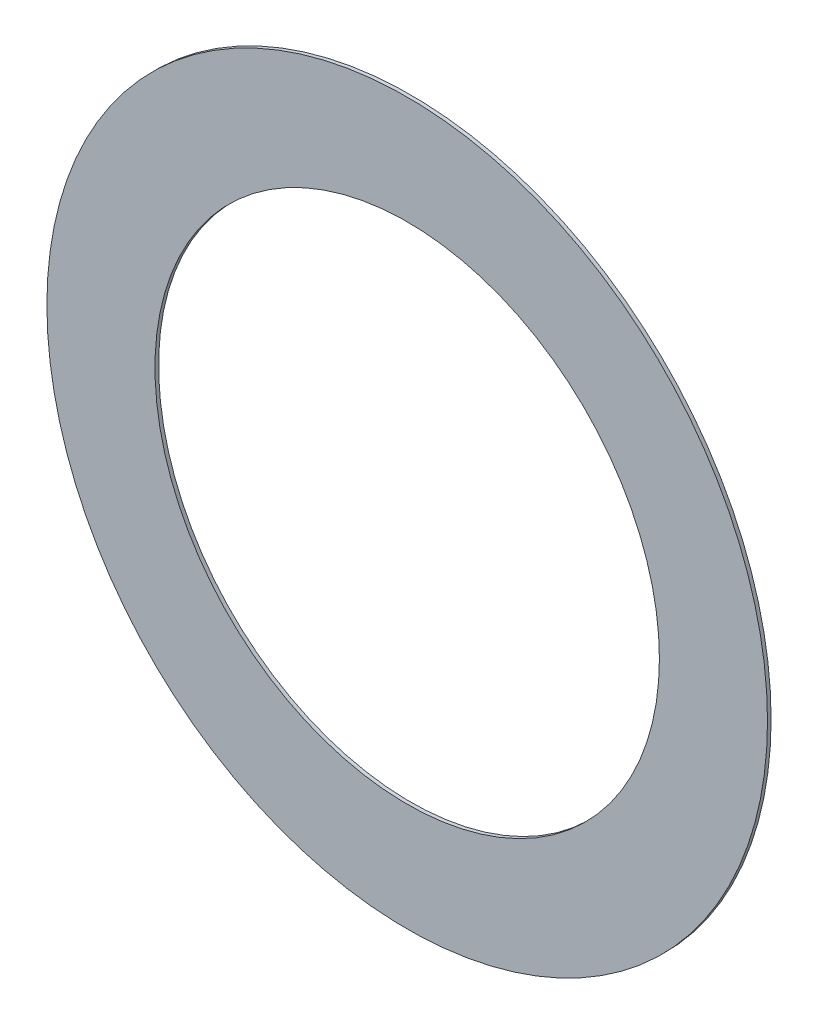
from build123d import *

# Parameters (mm, degrees)
SKETCH3_R           = 10
SKETCH3_R_2         = 7
BOSS_EXTRUDE1_DEPTH = 0.05


with BuildPart() as part:
    # Sketch3 → Boss-Extrude1 (new, symmetric)
    with BuildSketch(Plane.XY):
        Circle(SKETCH3_R)
        Circle(SKETCH3_R_2, mode=Mode.SUBTRACT)
    extrude(amount=BOSS_EXTRUDE1_DEPTH, both=True)


solid = part.part
